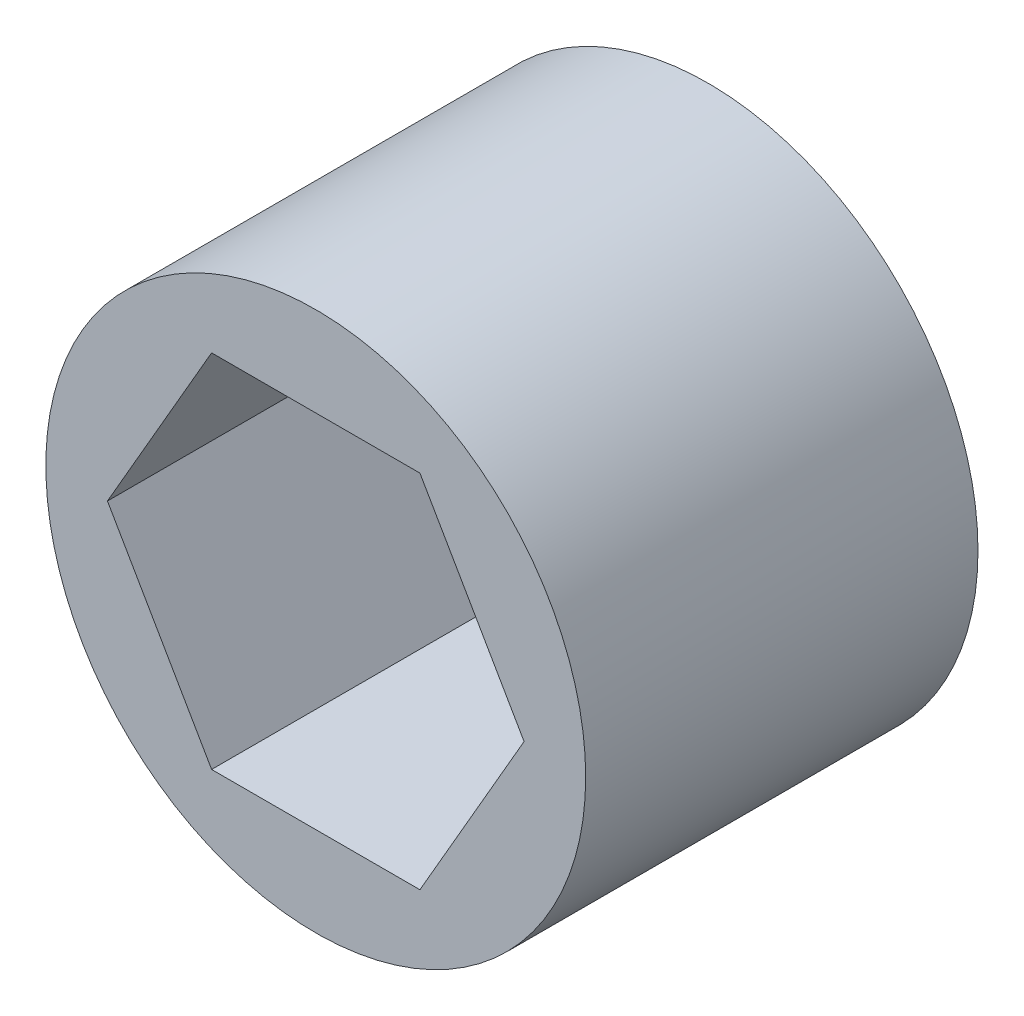
from build123d import *

# Parameters (mm, degrees)
SKETCH1_R           = 7.5
BOSS_EXTRUDE1_DEPTH = 5.45


with BuildPart() as part:
    # Sketch1 → Boss-Extrude1 (new, symmetric)
    with BuildSketch(Plane.XY):
        Circle(SKETCH1_R)
        Polygon((5.787936449, 0), (2.893968224, 5.0125), (-2.893968224, 5.0125), (-5.787936449, 0), (-2.893968224, -5.0125), (2.893968224, -5.0125), align=None, mode=Mode.SUBTRACT)
    extrude(amount=BOSS_EXTRUDE1_DEPTH, both=True)


solid = part.part
